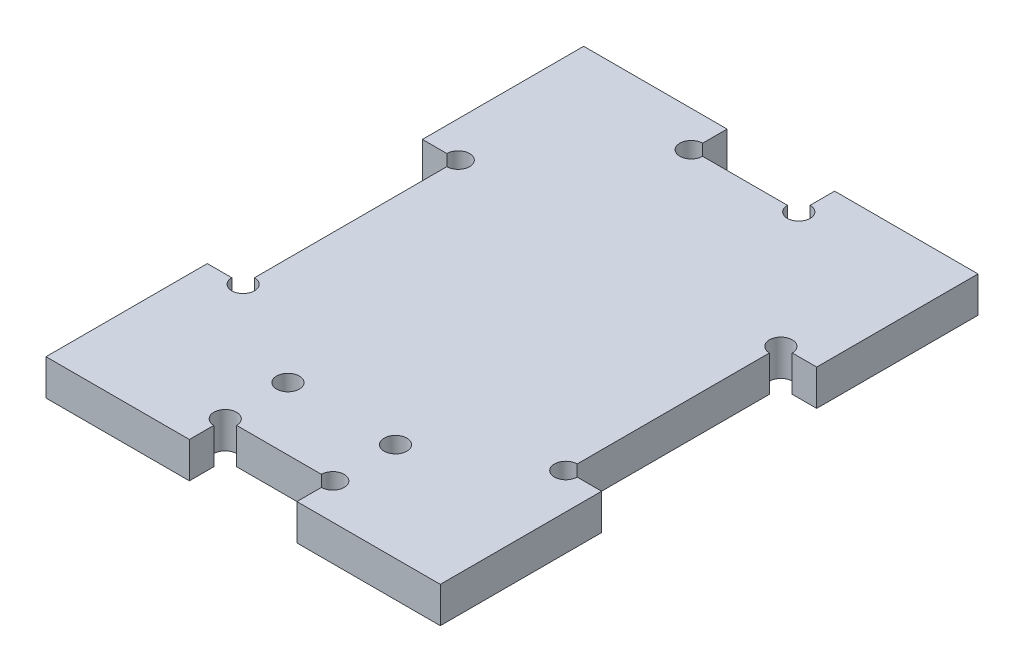
from build123d import *

# Parameters (mm, degrees)
SKETCH1_W               = 55
SKETCH1_H               = 75
BOSS_EXTRUDE1_DEPTH     = 5
SKETCH5_W               = 5
SKETCH5_H               = 30
SKETCH5_W_2             = 15
SKETCH5_H_2             = 5
CUT_EXTRUDE3_DEPTH      = 1
CUT_EXTRUDE3_DEPTH_BACK = 6
SKETCH6_R               = 1.5875
CUT_EXTRUDE4_DEPTH      = 6


with BuildPart() as part:
    # Sketch1 → Boss-Extrude1 (new body)
    with BuildSketch(Plane(origin=(0, 0, 0), x_dir=(1, 0, 0), z_dir=(0, 1, 0))):
        with Locations((27.5, 37.5)):
            Rectangle(SKETCH1_W, SKETCH1_H)
    extrude(amount=BOSS_EXTRUDE1_DEPTH)

    # Sketch5 → Cut-Extrude3 (cut, two sides)
    with BuildSketch(Plane(origin=(0, 5, 0), x_dir=(1, 0, 0), z_dir=(0, 1, 0))) as cut_extrude3_sk:
        with Locations((2.5, 37.5)):
            Rectangle(SKETCH5_W, SKETCH5_H)
        with Locations((27.5, 72.5)):
            Rectangle(SKETCH5_W_2, SKETCH5_H_2)
        with Locations((52.5, 37.5)):
            Rectangle(SKETCH5_W, SKETCH5_H)
        with Locations((27.5, 2.5)):
            Rectangle(SKETCH5_W_2, SKETCH5_H_2)
    extrude(amount=CUT_EXTRUDE3_DEPTH, mode=Mode.SUBTRACT)
    extrude(cut_extrude3_sk.sketch, amount=-CUT_EXTRUDE3_DEPTH_BACK, mode=Mode.SUBTRACT)

    # Sketch6 → Cut-Extrude4 (cut, through all)
    with BuildSketch(Plane(origin=(0, 5, 0), x_dir=(1, 0, 0), z_dir=(0, 1, 0))):
        with Locations((5, 52.5)):
            Circle(SKETCH6_R)
        with Locations((5, 22.5)):
            Circle(SKETCH6_R)
        with Locations((20, 5)):
            Circle(SKETCH6_R)
        with Locations((35, 5)):
            Circle(SKETCH6_R)
        with Locations((50, 22.5)):
            Circle(SKETCH6_R)
        with Locations((50, 52.5)):
            Circle(SKETCH6_R)
        with Locations((35, 70)):
            Circle(SKETCH6_R)
        with Locations((20, 70)):
            Circle(SKETCH6_R)
        with Locations((20, 13.75)):
            Circle(SKETCH6_R)
        with Locations((35, 13.75)):
            Circle(SKETCH6_R)
    extrude(amount=-CUT_EXTRUDE4_DEPTH, mode=Mode.SUBTRACT)


solid = part.part
